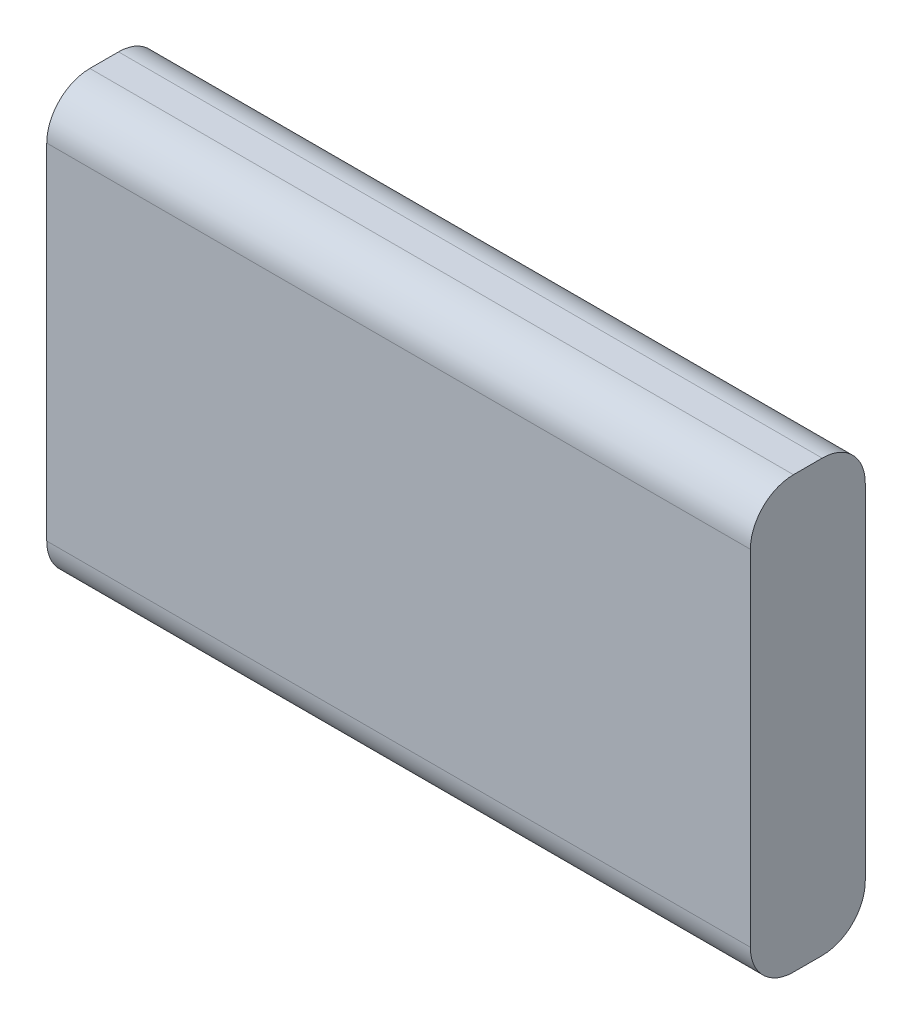
from build123d import *

# Parameters (mm, degrees)
SKETCH1_W           = 49
SKETCH1_H           = 30
BOSS_EXTRUDE1_DEPTH = 8
FILLET1_R           = 3


with BuildPart() as part:
    # Sketch1 → Boss-Extrude1 (new body)
    with BuildSketch(Plane.XY):
        with Locations((24.5, 15)):
            Rectangle(SKETCH1_W, SKETCH1_H)
    extrude(amount=BOSS_EXTRUDE1_DEPTH)

    # Fillet1
    fillet1_edges = [part.edges().sort_by_distance(p)[0] for p in [
        (24.5, 30, 8),
        (24.5, 30, 0),
        (24.5, 0, 0),
        (24.5, 0, 8),
    ]]
    fillet(fillet1_edges, radius=FILLET1_R)


solid = part.part
